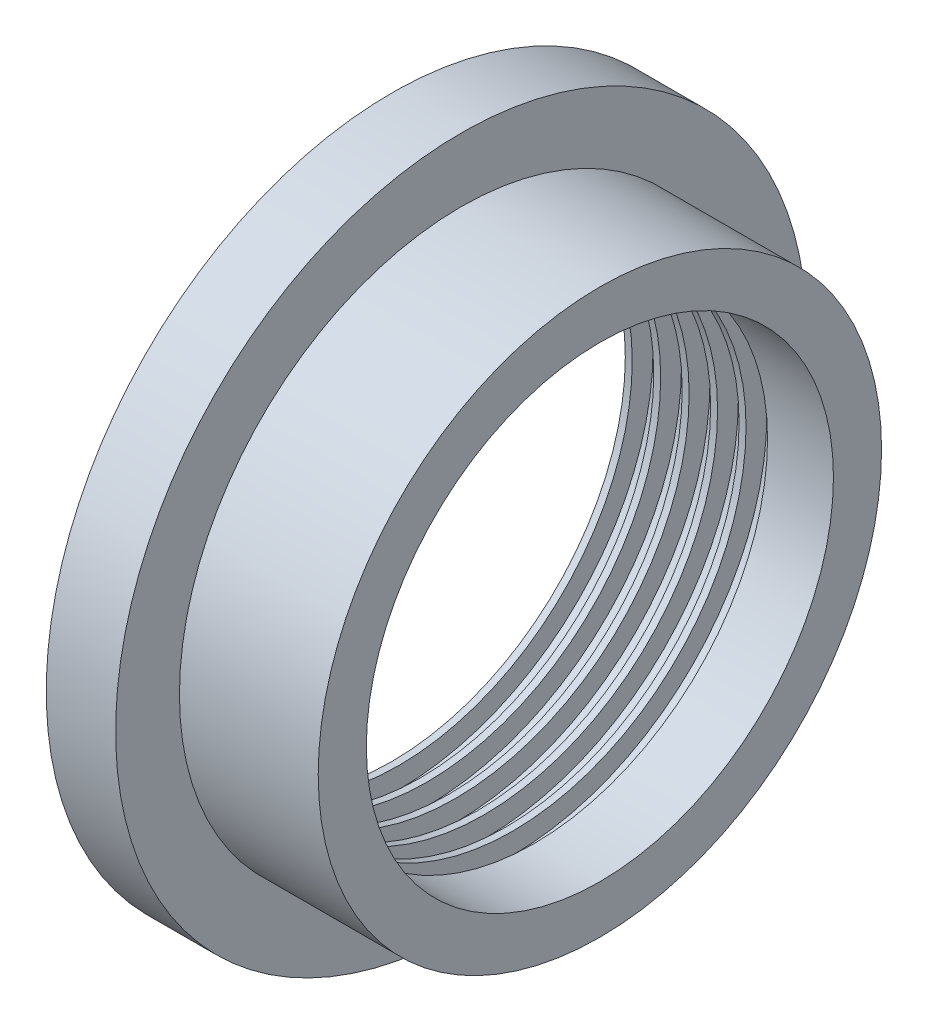
from build123d import *


with BuildPart() as part:
    # Sketch1 → Revolve1 (revolve)
    with BuildSketch(Plane.XY):
        Polygon((-7.62, 12.6492), (-7.62, 8.550800018), (-7.366, 8.550800018), (-7.366, 9.312800018), (-6.5786, 9.312800018), (-6.5786, 8.550800018), (-6.3246, 8.550800018), (-6.3246, 9.312800018), (-5.5372, 9.312800018), (-5.5372, 8.550800018), (-5.2832, 8.550800018), (-5.2832, 9.312800018), (-4.4958, 9.312800018), (-4.4958, 8.550800018), (-4.2418, 8.550800018), (-4.2418, 9.312800018), (-3.4544, 9.312800018), (-3.4544, 8.550800018), (-3.2004, 8.550800018), (-3.2004, 9.312800018), (-2.413, 9.312800018), (-2.413, 8.550800018), (0, 8.550800018), (0, 10.3124), (-5.08, 10.3124), (-5.08, 12.6492), align=None)
    revolve(axis=Axis((0, 0, 0), (-1, 0, 0)))


solid = part.part
